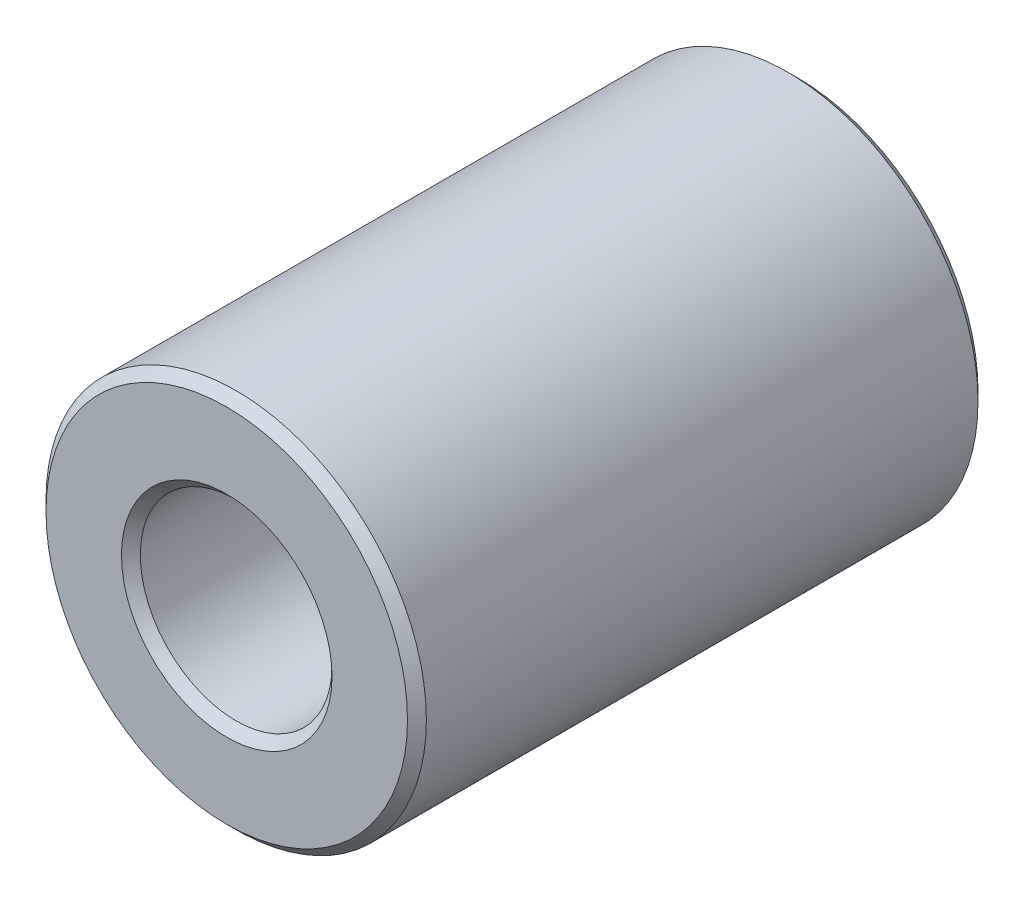
from build123d import *

# Parameters (mm, degrees)
BOSS_EXTRUDE1_DEPTH      = 9.525
BOSS_EXTRUDE1_DEPTH_BACK = 9.525
SKETCH3_R                = 6.35
SKETCH3_R_2              = 3.2004
CHAMFER1_SIZE            = 0.31496


with BuildPart() as part:
    # Sketch3 → Boss-Extrude1 (new, two sides: drawn at the far end of the back side and taken through both)
    with BuildSketch(Plane.XY.offset(-BOSS_EXTRUDE1_DEPTH_BACK)):
        Circle(SKETCH3_R)
        Circle(SKETCH3_R_2, mode=Mode.SUBTRACT)
    extrude(amount=BOSS_EXTRUDE1_DEPTH + BOSS_EXTRUDE1_DEPTH_BACK)

    # Chamfer1
    chamfer1_edges = [part.edges().sort_by_distance(p)[0] for p in [
        (-6.35, 0, -9.525),
        (-3.2004, 0, -9.525),
        (-6.35, 0, 9.525),
        (-3.2004, 0, 9.525),
    ]]
    chamfer(chamfer1_edges, length=CHAMFER1_SIZE)


solid = part.part
